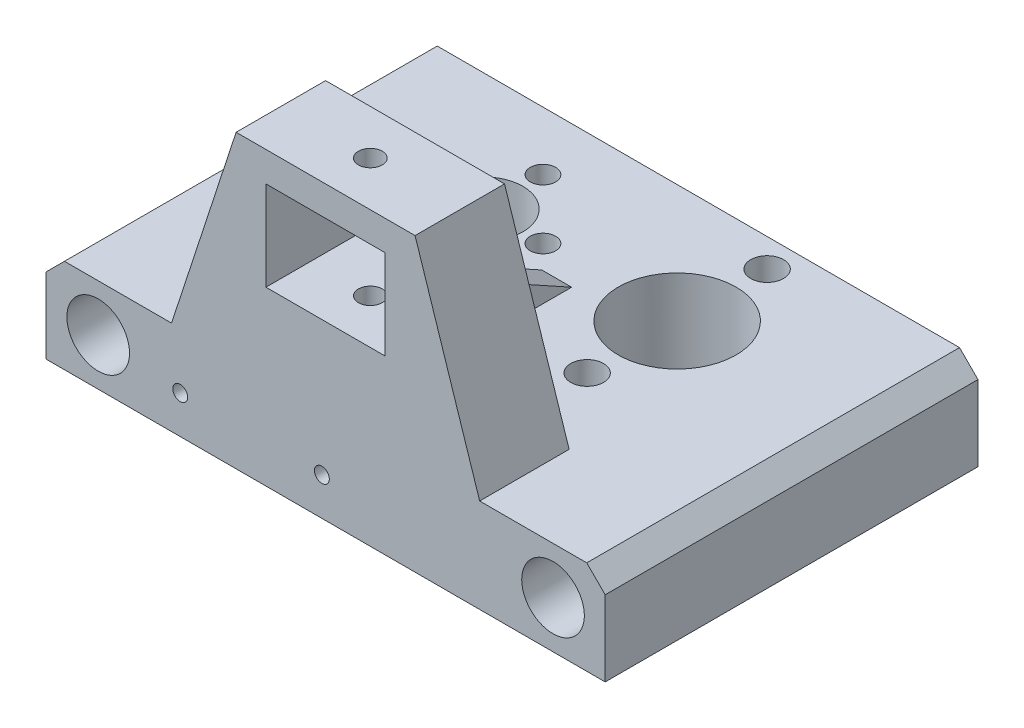
from build123d import *

# Parameters (mm, degrees)
SKETCH1_W           = 75
SKETCH1_H           = 50
SKETCH1_R           = 5.3
SKETCH1_R_2         = 7.9
BOSS_EXTRUDE1_DEPTH = 0.1
SKETCH2_W           = 12.5
SKETCH2_H           = 40
BOSS_EXTRUDE2_DEPTH = 12.5
SKETCH4_W           = 4
SKETCH4_H           = 12
BOSS_EXTRUDE3_DEPTH = 35
SKETCH5_W           = 24
SKETCH5_H           = 4
BOSS_EXTRUDE4_DEPTH = 12
SKETCH7_R           = 2.2
SKETCH7_R_2         = 1.7
CUT_EXTRUDE4_DEPTH  = 1.1
SKETCH8_W           = 16
SKETCH8_H           = 12
BOSS_EXTRUDE5_DEPTH = 23
BOSS_EXTRUDE6_DEPTH = 12
SKETCH6_R           = 1.6
CUT_EXTRUDE2_DEPTH  = 25
SKETCH10_W          = 4
SKETCH10_H          = 38
BOSS_EXTRUDE7_DEPTH = 2
BOSS_EXTRUDE8_DEPTH = 4
SKETCH12_W          = 5
SKETCH12_H          = 4.6
REVOLVE1_ANGLE      = 90
SKETCH14_R          = 2.2
SKETCH14_R_2        = 7.9
SKETCH14_R_3        = 1.7
SKETCH14_R_4        = 5.3
BOSS_EXTRUDE9_DEPTH = 12.5
SKETCH3_R           = 4.2
CUT_EXTRUDE1_DEPTH  = 51
SKETCH15_R          = 1
CUT_EXTRUDE5_DEPTH  = 8


with BuildPart() as part:
    # Sketch1 → Boss-Extrude1 (new body)
    with BuildSketch(Plane(origin=(0, 0, 0), x_dir=(1, 0, 0), z_dir=(0, 1, 0))):
        with Locations((37.5, 25)):
            Rectangle(SKETCH1_W, SKETCH1_H)
        with Locations((24.5, 34.15)):
            Circle(SKETCH1_R, mode=Mode.SUBTRACT)
        with Locations((50.5, 34.15)):
            Circle(SKETCH1_R_2, mode=Mode.SUBTRACT)
    extrude(amount=BOSS_EXTRUDE1_DEPTH)

    # Sketch2 → Boss-Extrude2 (add)
    with BuildSketch(Plane(origin=(0, 0.1, 0), x_dir=(1, 0, 0), z_dir=(0, 1, 0))):
        with Locations((6.25, 30)):
            Rectangle(SKETCH2_W, SKETCH2_H)
        with Locations((68.75, 30)):
            Rectangle(SKETCH2_W, SKETCH2_H)
    extrude(amount=BOSS_EXTRUDE2_DEPTH)

    # Sketch4 → Boss-Extrude3 (add)
    with BuildSketch(Plane(origin=(0, 0.1, 0), x_dir=(1, 0, 0), z_dir=(0, 1, 0))):
        with Locations((47.5, 6)):
            Rectangle(SKETCH4_W, SKETCH4_H)
        with Locations((27.5, 6)):
            Rectangle(SKETCH4_W, SKETCH4_H)
    extrude(amount=BOSS_EXTRUDE3_DEPTH)

    # Sketch5 → Boss-Extrude4 (add)
    with BuildSketch(Plane(origin=(0, 0, -12), x_dir=(-1, 0, 0), z_dir=(0, 0, -1))):
        with Locations((-37.5, 37.1)):
            Rectangle(SKETCH5_W, SKETCH5_H)
    extrude(amount=-BOSS_EXTRUDE4_DEPTH)

    # Sketch7 → Cut-Extrude4 (cut, through all)
    with BuildSketch(Plane(origin=(0, 0.1, 0), x_dir=(1, 0, 0), z_dir=(0, 1, 0))):
        with Locations((50.5, 22.08)):
            Circle(SKETCH7_R)
        with Locations((50.5, 46.215)):
            Circle(SKETCH7_R)
        with Locations((24.5, 42.15)):
            Circle(SKETCH7_R_2)
        with Locations((16.5, 34.15)):
            Circle(SKETCH7_R_2)
        with Locations((32.5, 34.15)):
            Circle(SKETCH7_R_2)
        with Locations((24.5, 26.15)):
            Circle(SKETCH7_R_2)
    extrude(amount=-CUT_EXTRUDE4_DEPTH, mode=Mode.SUBTRACT)

    # Sketch8 → Boss-Extrude5 (add)
    with BuildSketch(Plane(origin=(0, 0.1, 0), x_dir=(1, 0, 0), z_dir=(0, 1, 0))):
        with Locations((37.5, 6)):
            Rectangle(SKETCH8_W, SKETCH8_H)
    extrude(amount=BOSS_EXTRUDE5_DEPTH)

    # Sketch9 → Boss-Extrude6 (add)
    with BuildSketch(Plane.XY):
        Polygon((49.5, 39.1), (62.25, 0.1), (49.5, 0.1), align=None)
        Polygon((12.75, 0.1), (25.5, 0.1), (25.5, 39.1), align=None)
    extrude(amount=-BOSS_EXTRUDE6_DEPTH)

    # Sketch6 → Cut-Extrude2 (cut)
    with BuildSketch(Plane(origin=(0, 39.1, 0), x_dir=(1, 0, 0), z_dir=(0, 1, 0))):
        with Locations((37.5, 6)):
            Circle(SKETCH6_R)
    extrude(amount=-CUT_EXTRUDE2_DEPTH, mode=Mode.SUBTRACT)

    # Sketch10 → Boss-Extrude7 (add)
    with BuildSketch(Plane(origin=(0, 0.1, 0), x_dir=(1, 0, 0), z_dir=(0, 1, 0))):
        with Locations((37.5, 31)):
            Rectangle(SKETCH10_W, SKETCH10_H)
    extrude(amount=BOSS_EXTRUDE7_DEPTH)

    # Sketch11 → Boss-Extrude8 (add)
    with BuildSketch(Plane(origin=(39.5, 0, 0), x_dir=(0, 0, -1), z_dir=(1, 0, 0))):
        Polygon((50, 2.1), (12, 2.1), (12, 23.1), align=None)
    extrude(amount=-BOSS_EXTRUDE8_DEPTH)

    # Sketch12 → Revolve1 (revolve)
    with BuildSketch(Plane(origin=(0, 0.1, 0), x_dir=(1, 0, 0), z_dir=(0, 1, 0))):
        with Locations((42, 14.3)):
            Rectangle(SKETCH12_W, SKETCH12_H)
        with Locations((33, 14.3)):
            Rectangle(SKETCH12_W, SKETCH12_H)
    revolve(axis=Axis((39.5, 0.1, -12), (1, 0, 0)), revolution_arc=REVOLVE1_ANGLE)

    # Sketch14 → Boss-Extrude9 (add)
    with BuildSketch(Plane(origin=(0, 0.1, 0), x_dir=(1, 0, 0), z_dir=(0, 1, 0))):
        Polygon((62.25, 12), (62.25, 10), (62.5, 10), (62.5, 50), (39.5, 50), (39.5, 16.6), (44.5, 16.6), (44.5, 12), align=None)
        with Locations((50.5, 22.08)):
            Circle(SKETCH14_R, mode=Mode.SUBTRACT)
        with Locations((50.5, 34.15)):
            Circle(SKETCH14_R_2, mode=Mode.SUBTRACT)
        with Locations((50.5, 46.215)):
            Circle(SKETCH14_R, mode=Mode.SUBTRACT)
        Polygon((62.25, 0), (75, 0), (75, 10), (62.5, 10), (62.25, 10), align=None)
        Polygon((12.5, 10), (62.25, 10), (62.25, 12), (44.5, 12), (44.5, 16.6), (39.5, 16.6), (39.5, 50), (12.5, 50), align=None)
        with Locations((16.5, 34.15)):
            Circle(SKETCH14_R_3, mode=Mode.SUBTRACT)
        with Locations((24.5, 26.15)):
            Circle(SKETCH14_R_3, mode=Mode.SUBTRACT)
        with Locations((24.5, 34.15)):
            Circle(SKETCH14_R_4, mode=Mode.SUBTRACT)
        with Locations((32.5, 34.15)):
            Circle(SKETCH14_R_3, mode=Mode.SUBTRACT)
        with Locations((24.5, 42.15)):
            Circle(SKETCH14_R_3, mode=Mode.SUBTRACT)
        Polygon((0, 0), (62.25, 0), (62.25, 10), (12.5, 10), (0, 10), align=None)
    extrude(amount=BOSS_EXTRUDE9_DEPTH)

    # Sketch3 → Cut-Extrude1 (cut, through all)
    with BuildSketch(Plane(origin=(0, 0, -50), x_dir=(-1, 0, 0), z_dir=(0, 0, -1))):
        with Locations((-68, 6.3)):
            Circle(SKETCH3_R)
        with Locations((-7, 6.3)):
            Circle(SKETCH3_R)
        Polygon((-72.525126266, 12.6), (-75, 12.6), (-75, 10.125126266), align=None)
        Polygon((0, 10.125126266), (-2.474873734, 12.6), (0, 12.6), align=None)
    extrude(amount=-CUT_EXTRUDE1_DEPTH, mode=Mode.SUBTRACT)

    # Sketch15 → Cut-Extrude5 (cut)
    with BuildSketch(Plane.XY):
        with Locations((18, 5.062563133)):
            Circle(SKETCH15_R)
        with Locations((37, 5.062563133)):
            Circle(SKETCH15_R)
    extrude(amount=-CUT_EXTRUDE5_DEPTH, mode=Mode.SUBTRACT)


solid = part.part
